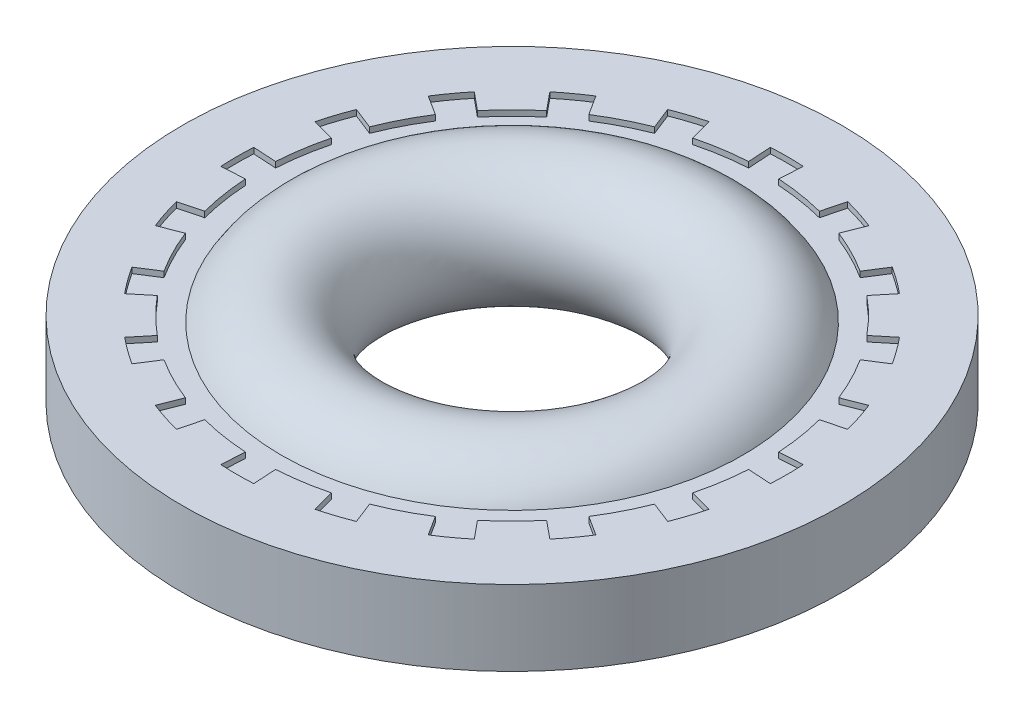
from build123d import *

# Parameters (mm, degrees)
SKETCH2_W          = 1.15038124
SKETCH2_H          = 1.1176
CUT_EXTRUDE1_DEPTH = 2.1176
CIRPATTERN1_COUNT  = 20


with BuildPart() as part:
    # Sketch2 → Revolve1 (revolve)
    with BuildSketch(Plane.XY):
        with Locations((-4.31430938, 0)):
            Rectangle(SKETCH2_W, SKETCH2_H)
    revolve(axis=Axis((0, 0, 0), (0, 1, 0)))

    # Sketch3 → Cut-Extrude1 (cut, through all)
    with BuildSketch(Plane(origin=(0, 0.5588, 0), x_dir=(1, 0, 0), z_dir=(0, 1, 0))):
        with BuildLine():
            Line((-0.223854065, 3.732411882), (-0.244475, 4.0762333))
            ThreePointArc((-0.244475, 4.0762333), (0, 4.083558), (0.244475, 4.0762333))
            Line((0.244475, 4.0762333), (0.223854065, 3.732411882))
            ThreePointArc((0.223854065, 3.732411882), (0, 3.73911876), (-0.223854065, 3.732411882))
        make_face()
    cut_extrude1 = extrude(amount=-CUT_EXTRUDE1_DEPTH, mode=Mode.SUBTRACT)

    # CirPattern1: Cut-Extrude1 ×20 about axis
    cirpattern1_axis = Axis((0, 0, 0), (0, 1, 0))
    for i in range(1, CIRPATTERN1_COUNT):
        add(cut_extrude1.rotate(cirpattern1_axis, i * 360 / CIRPATTERN1_COUNT), mode=Mode.SUBTRACT)

    # Sketch4 → Revolve2 (revolve)
    with BuildSketch(Plane.XY):
        with BuildLine():
            Line((-4.083558, -0.47498), (-3.423649493, -0.47498))
            ThreePointArc((-3.423649493, -0.47498), (-1.651, 0), (-3.423649493, 0.47498))
            Line((-3.423649493, 0.47498), (-4.083558, 0.47498))
            Line((-4.083558, 0.47498), (-4.083558, -0.47498))
        make_face()
    revolve(axis=Axis((0, 0, 0), (0, 1, 0)))


solid = part.part
